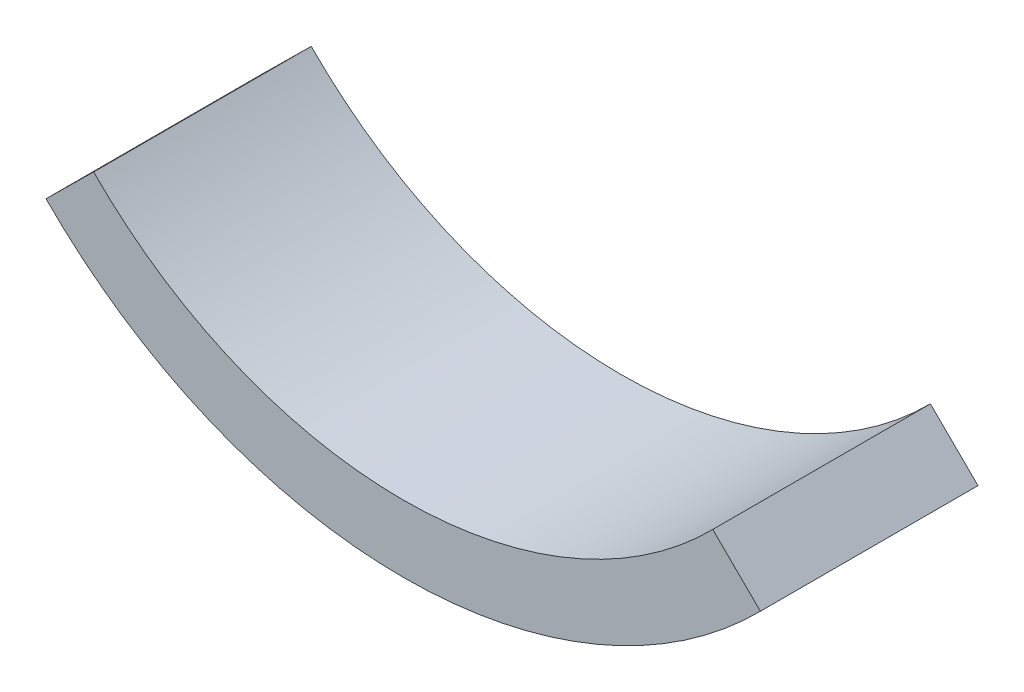
from build123d import *

# Parameters (mm, degrees)
BOSS_EXTRUDE1_DEPTH = 13


with BuildPart() as part:
    # Sketch1 → Boss-Extrude1 (new body)
    with BuildSketch(Plane.XY):
        with BuildLine():
            Line((-18.49541387, -18.273468904), (-21.340862158, -21.084771812))
            ThreePointArc((-21.340862158, -21.084771812), (0, -30), (21.340862158, -21.084771812))
            Line((21.340862158, -21.084771812), (18.49541387, -18.273468904))
            ThreePointArc((18.49541387, -18.273468904), (0, -26), (-18.49541387, -18.273468904))
        make_face()
    extrude(amount=BOSS_EXTRUDE1_DEPTH)


solid = part.part
